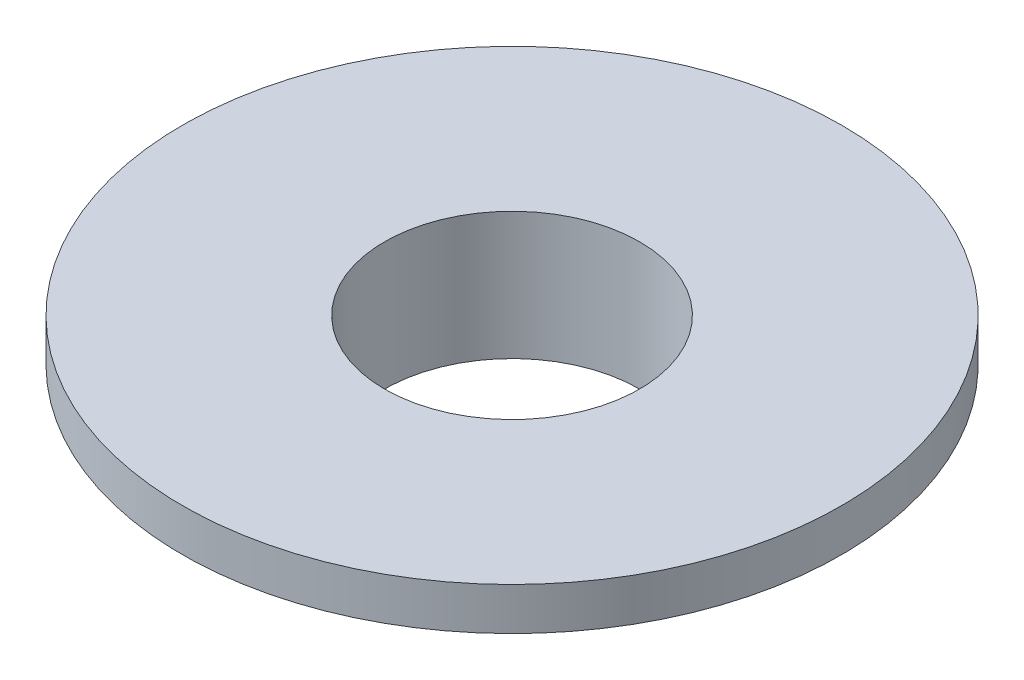
from build123d import *


with BuildPart() as part:
    # Эскиз1 → Повернуть1 (revolve)
    with BuildSketch(Plane.XY):
        Polygon((6, 0), (6, 6), (15.5, 6), (15.5, 4), (6.7, 4), (6.7, 0), align=None)
    revolve(axis=Axis((0, 0, 0), (0, 1, 0)))


solid = part.part
